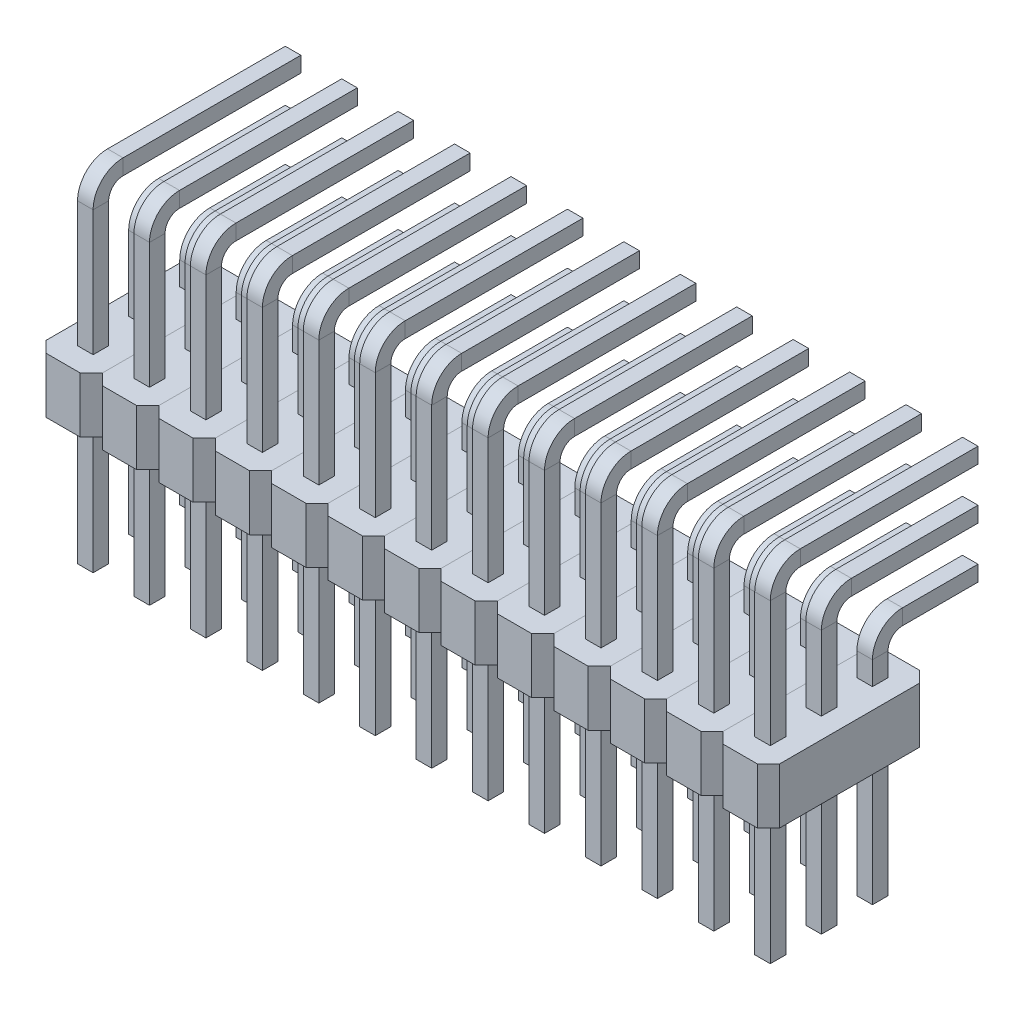
from build123d import *

# Parameters (mm, degrees)
SKETCH1_W           = 0.7
SKETCH1_H           = 0.7
SKETCH1_5_W         = 0.7
SKETCH1_5_H         = 0.7
SKETCH1_6_W         = 0.7
SKETCH1_6_H         = 0.7
SKETCH1_7_W         = 2.54
SKETCH1_7_H         = 7.3
SKETCH1_7_W_2       = 0.7
SKETCH1_7_H_2       = 0.7
BOSS_EXTRUDE1_DEPTH = 2.5
CHAMFER1_SIZE       = 0.5
LPATTERN1_COUNT     = 13
LPATTERN1_PITCH     = 2.54


with BuildPart() as part:
    # Sweep3: sweep along a path in Sketch2
    with BuildLine(Plane(origin=(1.25, 0, 0), x_dir=(0, 0, -1), z_dir=(1, 0, 0))) as sweep3_path:
        Line((-5.95, -6), (-5.95, 8.15))
        ThreePointArc((-5.95, 8.15), (-5.657106781, 8.857106781), (-4.95, 9.15))
        Line((-4.95, 9.15), (3.05, 9.15))
    # Sketch1 → Sweep3 (sweep)
    with BuildSketch(Plane(origin=(0, 0, 0), x_dir=(1, 0, 0), z_dir=(0, 1, 0))):
        with Locations((1.27, -5.95)):
            Rectangle(SKETCH1_W, SKETCH1_H)
    sweep(path=sweep3_path.line)



with BuildPart() as body_2:
    # Sweep4: sweep along a path in Sketch2_6
    with BuildLine(Plane(origin=(1.25, 0, 0), x_dir=(0, 0, -1), z_dir=(1, 0, 0))) as sweep4_path:
        Line((-3.65, -6), (-3.65, 5.85))
        ThreePointArc((-3.65, 5.85), (-3.357106781, 6.557106781), (-2.65, 6.85))
        Line((-2.65, 6.85), (3.05, 6.85))
    # Sketch1_5 → Sweep4 (sweep)
    with BuildSketch(Plane(origin=(0, 0, 0), x_dir=(1, 0, 0), z_dir=(0, 1, 0))):
        with Locations((1.27, -3.65)):
            Rectangle(SKETCH1_5_W, SKETCH1_5_H)
    sweep(path=sweep4_path.line)


with BuildPart() as body_3:
    # Sweep5: sweep along a path in Sketch2_7
    with BuildLine(Plane(origin=(1.25, 0, 0), x_dir=(0, 0, -1), z_dir=(1, 0, 0))) as sweep5_path:
        Line((-1.35, -6), (-1.35, 3.55))
        ThreePointArc((-1.35, 3.55), (-1.057106781, 4.257106781), (-0.35, 4.55))
        Line((-0.35, 4.55), (3.05, 4.55))
    # Sketch1_6 → Sweep5 (sweep)
    with BuildSketch(Plane(origin=(0, 0, 0), x_dir=(1, 0, 0), z_dir=(0, 1, 0))):
        with Locations((1.27, -1.35)):
            Rectangle(SKETCH1_6_W, SKETCH1_6_H)
    sweep(path=sweep5_path.line)


with BuildPart() as part_1:
    add(part.part)

    add(body_2.part)  # Boss-Extrude1 merges body 2

    add(body_3.part)  # Boss-Extrude1 merges body 3
    # Sketch1_7 → Boss-Extrude1 (add)
    with BuildSketch(Plane(origin=(0, 0, 0), x_dir=(1, 0, 0), z_dir=(0, 1, 0))):
        with Locations((1.27, -3.65)):
            Rectangle(SKETCH1_7_W, SKETCH1_7_H)
        with Locations((1.27, -5.95)):
            Rectangle(SKETCH1_7_W_2, SKETCH1_7_H_2, mode=Mode.SUBTRACT)
        with Locations((1.27, -3.65)):
            Rectangle(SKETCH1_7_W_2, SKETCH1_7_H_2, mode=Mode.SUBTRACT)
        with Locations((1.27, -1.35)):
            Rectangle(SKETCH1_7_W_2, SKETCH1_7_H_2, mode=Mode.SUBTRACT)
    extrude(amount=BOSS_EXTRUDE1_DEPTH)

    # Chamfer1
    chamfer1_edges = [part_1.edges().sort_by_distance(p)[0] for p in [
        (0, 1.25, 0),
        (2.54, 1.25, 0),
        (0, 1.25, 7.3),
        (2.54, 1.25, 7.3),
    ]]
    chamfer(chamfer1_edges, length=CHAMFER1_SIZE)


with BuildPart() as lpattern1_1:
    # LPattern1: pattern copy
    add(part_1.part.moved(Location(Vector(1, 0, 0) * (1 * LPATTERN1_PITCH))))


with BuildPart() as lpattern1_2:
    # LPattern1: pattern copy
    add(part_1.part.moved(Location(Vector(1, 0, 0) * (2 * LPATTERN1_PITCH))))


with BuildPart() as lpattern1_3:
    # LPattern1: pattern copy
    add(part_1.part.moved(Location(Vector(1, 0, 0) * (3 * LPATTERN1_PITCH))))


with BuildPart() as lpattern1_4:
    # LPattern1: pattern copy
    add(part_1.part.moved(Location(Vector(1, 0, 0) * (4 * LPATTERN1_PITCH))))


with BuildPart() as lpattern1_5:
    # LPattern1: pattern copy
    add(part_1.part.moved(Location(Vector(1, 0, 0) * (5 * LPATTERN1_PITCH))))


with BuildPart() as lpattern1_6:
    # LPattern1: pattern copy
    add(part_1.part.moved(Location(Vector(1, 0, 0) * (6 * LPATTERN1_PITCH))))


with BuildPart() as lpattern1_7:
    # LPattern1: pattern copy
    add(part_1.part.moved(Location(Vector(1, 0, 0) * (7 * LPATTERN1_PITCH))))


with BuildPart() as lpattern1_8:
    # LPattern1: pattern copy
    add(part_1.part.moved(Location(Vector(1, 0, 0) * (8 * LPATTERN1_PITCH))))


with BuildPart() as lpattern1_9:
    # LPattern1: pattern copy
    add(part_1.part.moved(Location(Vector(1, 0, 0) * (9 * LPATTERN1_PITCH))))


with BuildPart() as lpattern1_10:
    # LPattern1: pattern copy
    add(part_1.part.moved(Location(Vector(1, 0, 0) * (10 * LPATTERN1_PITCH))))


with BuildPart() as lpattern1_11:
    # LPattern1: pattern copy
    add(part_1.part.moved(Location(Vector(1, 0, 0) * (11 * LPATTERN1_PITCH))))


with BuildPart() as lpattern1_12:
    # LPattern1: pattern copy
    add(part_1.part.moved(Location(Vector(1, 0, 0) * (12 * LPATTERN1_PITCH))))


solid = Compound([part_1.part, lpattern1_1.part, lpattern1_2.part, lpattern1_3.part, lpattern1_4.part, lpattern1_5.part, lpattern1_6.part, lpattern1_7.part, lpattern1_8.part, lpattern1_9.part, lpattern1_10.part, lpattern1_11.part, lpattern1_12.part])
